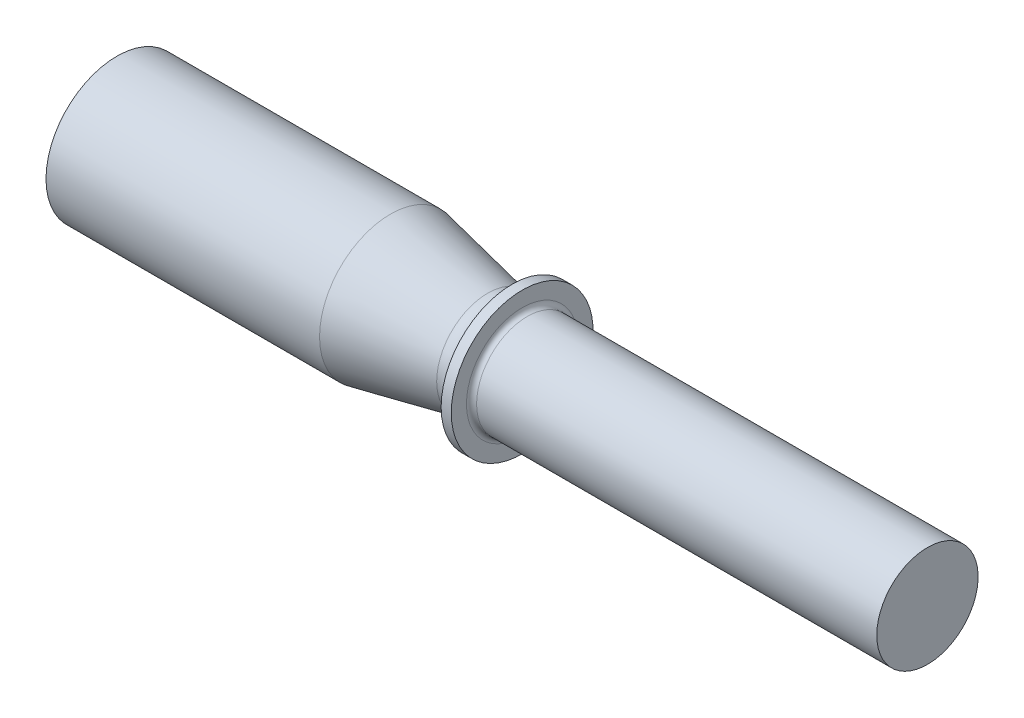
from build123d import *

# Parameters (mm, degrees)
FILLET1_R = 1.27


with BuildPart() as part:
    # Sketch1 → Revolve1 (revolve)
    with BuildSketch(Plane.XY):
        with BuildLine():
            Line((0, 17.78), (0, 0))
            Line((0, 0), (203.2, 0))
            Line((203.2, 0), (203.2, 12.7))
            Line((203.2, 12.7), (101.6, 12.7))
            Line((101.6, 12.7), (101.6, 17.78))
            Line((101.6, 17.78), (99.06, 17.78))
            ThreePointArc((99.06, 17.78), (97.192874103, 13.84504892), (92.964, 12.802636843))
            Line((92.964, 12.802636843), (68.58, 17.78))
            Line((68.58, 17.78), (0, 17.78))
        make_face()
    revolve(axis=Axis((-70.891441255, 0, 0), (1, 0, 0)))

    # Fillet1
    fillet1_edges = [part.edges().sort_by_distance(p)[0] for p in [
        (101.6, -12.7, 0),
    ]]
    fillet(fillet1_edges, radius=FILLET1_R)


solid = part.part
